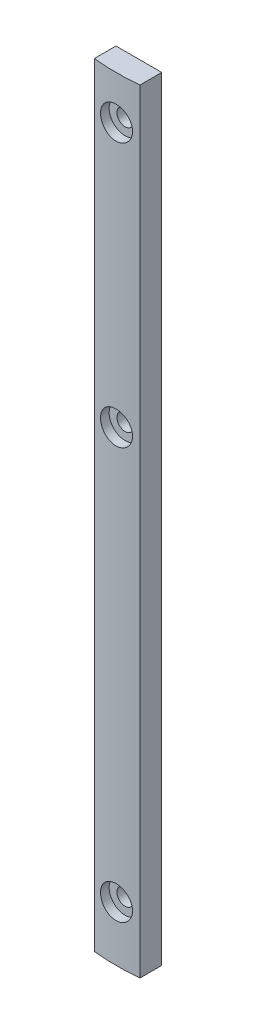
from build123d import *

# Parameters (mm, degrees)
EXTRUDE_1_DEPTH              = 169
HOLE_WIZARD_M3_1_D           = 3.6
HOLE_WIZARD_M3_1_DEPTH       = 5
HOLE_WIZARD_M3_1_CBORE_D     = 7
HOLE_WIZARD_M3_1_CBORE_DEPTH = 2


with BuildPart() as part:
    # 草图1 → 凸台-拉伸1 (new body)
    with BuildSketch(Plane(origin=(0, 169, 0), x_dir=(1, 0, 0), z_dir=(0, 1, 0))):
        with BuildLine():
            Line((1095, -2.499371855), (1095, 2.25))
            Line((1095, 2.25), (1085, 2.25))
            Line((1085, 2.25), (1085, -2.499371855))
            ThreePointArc((1085, -2.499371855), (1090, -2.75), (1095, -2.499371855))
        make_face()
    extrude(amount=-EXTRUDE_1_DEPTH)

    # M3 六角头机械螺钉的柱形沉头孔1
    with Locations(Plane(origin=(1090, 101.825, 2.75), x_dir=(0, 1, 0), z_dir=(0, 0, 1))):
        with Locations((0, 0)):
            CounterBoreHole(HOLE_WIZARD_M3_1_D / 2, HOLE_WIZARD_M3_1_CBORE_D / 2, HOLE_WIZARD_M3_1_CBORE_DEPTH, depth=HOLE_WIZARD_M3_1_DEPTH)

    # 草图4 → 切除-旋转1 (revolve, cut)
    with BuildSketch(Plane(origin=(1090, 0, 0), x_dir=(0, 0, -1), z_dir=(1, 0, 0))):
        Polygon((-2.75, 159.5), (-2.75, 156), (-0.75, 156), (-0.75, 157.7), (2.25, 157.7), (2.25, 159.5), align=None)
    revolve(axis=Axis((1090, 159.5, -2.25), (0, 0, 1)), mode=Mode.SUBTRACT)

    # 草图5 → 切除-旋转2 (revolve, cut)
    with BuildSketch(Plane(origin=(1090, 0, 0), x_dir=(0, 0, -1), z_dir=(1, 0, 0))):
        Polygon((-2.75, 12), (-2.75, 8.5), (-0.75, 8.5), (-0.75, 10.2), (2.25, 10.2), (2.25, 12), align=None)
    revolve(axis=Axis((1090, 12, 2.75), (0, 0, -1)), mode=Mode.SUBTRACT)


solid = part.part
